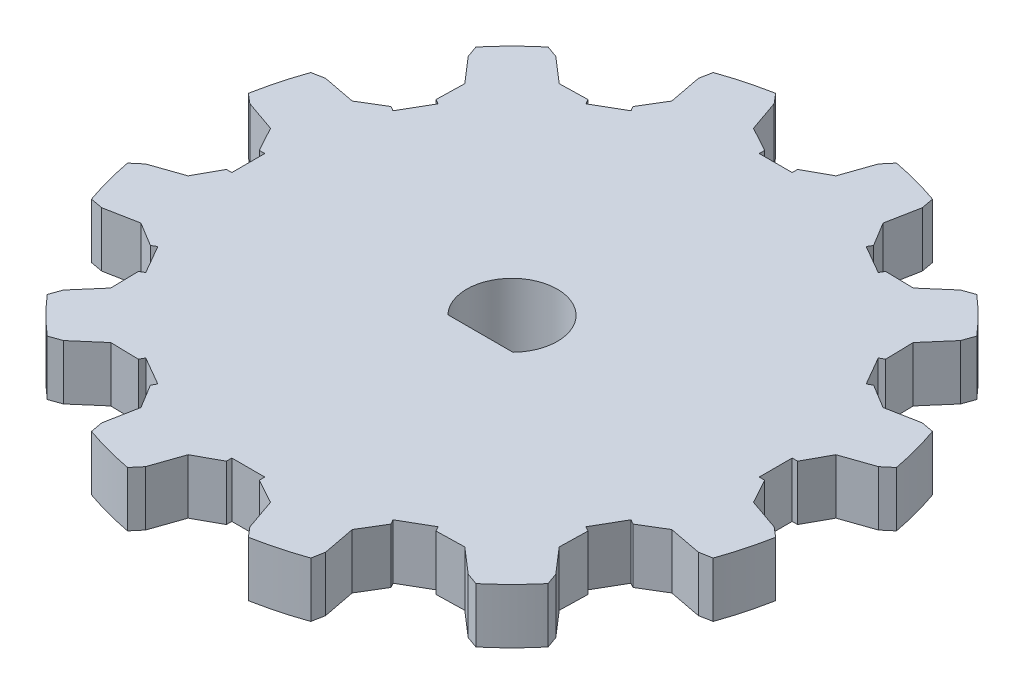
from build123d import *

# Parameters (mm, degrees)
BOSS_EXTRUDE1_DEPTH     = 5
SKETCH5_R               = 17.5
BOSS_EXTRUDE2_DEPTH     = 2.5
CUT_EXTRUDE2_DEPTH      = 1
CUT_EXTRUDE2_DEPTH_BACK = 8.5


with BuildPart() as part:
    # Sketch1 → Boss-Extrude1 (new body)
    with BuildSketch(Plane(origin=(0, 0, 0), x_dir=(1, 0, 0), z_dir=(0, 1, 0))):
        with BuildLine():
            Line((-1.5, 24.494818027), (-3.75, 25.728146066))
            Line((-3.75, 25.728146066), (-4.75, 28.608346684))
            Line((-4.75, 28.608346684), (-5.5, 29.491524206))
            ThreePointArc((-5.5, 29.491524206), (-6.518225952, 29.283318296), (-7.528629065, 29.039968051))
            ThreePointArc((-7.528629065, 29.039968051), (-7.764571353, 28.977774789), (-8, 28.91366459))
            ThreePointArc((-8, 28.91366459), (-8.996709886, 28.619210528), (-9.982622382, 28.290409159))
            Line((-9.982622382, 28.290409159), (-10.190552674, 27.150554989))
            Line((-10.190552674, 27.150554989), (-9.616477769, 24.156228086))
            Line((-9.616477769, 24.156228086), (-10.948370908, 21.963134673))
            Line((-10.948370908, 21.963134673), (-10.700961894, 21.534609691))
            Line((-10.700961894, 21.534609691), (-13.299038106, 20.034609691))
            Line((-13.299038106, 20.034609691), (-13.546447119, 20.463134673))
            Line((-13.546447119, 20.463134673), (-16.111668297, 20.406228086))
            Line((-16.111668297, 20.406228086), (-18.41779401, 22.400554989))
            Line((-18.41779401, 22.400554989), (-19.508901824, 22.790409159))
            ThreePointArc((-19.508901824, 22.790409159), (-20.28660841, 22.100984575), (-21.039968051, 21.385035525))
            ThreePointArc((-21.039968051, 21.385035525), (-21.213203436, 21.213203436), (-21.385035525, 21.039968051))
            ThreePointArc((-21.385035525, 21.039968051), (-22.100984575, 20.28660841), (-22.790409159, 19.508901824))
            Line((-22.790409159, 19.508901824), (-22.400554989, 18.41779401))
            Line((-22.400554989, 18.41779401), (-20.406228086, 16.111668297))
            Line((-20.406228086, 16.111668297), (-20.463134673, 13.546447119))
            Line((-20.463134673, 13.546447119), (-20.034609691, 13.299038106))
            Line((-20.034609691, 13.299038106), (-21.534609691, 10.700961894))
            Line((-21.534609691, 10.700961894), (-21.963134673, 10.948370908))
            Line((-21.963134673, 10.948370908), (-24.156228086, 9.616477769))
            Line((-24.156228086, 9.616477769), (-27.150554989, 10.190552674))
            Line((-27.150554989, 10.190552674), (-28.290409159, 9.982622382))
            ThreePointArc((-28.290409159, 9.982622382), (-28.619210528, 8.996709886), (-28.91366459, 8))
            ThreePointArc((-28.91366459, 8), (-28.977774789, 7.764571353), (-29.039968051, 7.528629065))
            ThreePointArc((-29.039968051, 7.528629065), (-29.283318296, 6.518225952), (-29.491524206, 5.5))
            Line((-29.491524206, 5.5), (-28.608346684, 4.75))
            Line((-28.608346684, 4.75), (-25.728146066, 3.75))
            Line((-25.728146066, 3.75), (-24.494818027, 1.5))
            Line((-24.494818027, 1.5), (-24, 1.5))
            Line((-24, 1.5), (-24, -1.5))
            Line((-24, -1.5), (-24.494818027, -1.5))
            Line((-24.494818027, -1.5), (-25.728146066, -3.75))
            Line((-25.728146066, -3.75), (-28.608346684, -4.75))
            Line((-28.608346684, -4.75), (-29.491524206, -5.5))
            ThreePointArc((-29.491524206, -5.5), (-29.283318296, -6.518225952), (-29.039968051, -7.528629065))
            ThreePointArc((-29.039968051, -7.528629065), (-28.977774789, -7.764571353), (-28.91366459, -8))
            ThreePointArc((-28.91366459, -8), (-28.619210528, -8.996709886), (-28.290409159, -9.982622382))
            Line((-28.290409159, -9.982622382), (-27.150554989, -10.190552674))
            Line((-27.150554989, -10.190552674), (-24.156228086, -9.616477769))
            Line((-24.156228086, -9.616477769), (-21.963134673, -10.948370908))
            Line((-21.963134673, -10.948370908), (-21.534609691, -10.700961894))
            Line((-21.534609691, -10.700961894), (-20.034609691, -13.299038106))
            Line((-20.034609691, -13.299038106), (-20.463134673, -13.546447119))
            Line((-20.463134673, -13.546447119), (-20.406228086, -16.111668297))
            Line((-20.406228086, -16.111668297), (-22.400554989, -18.41779401))
            Line((-22.400554989, -18.41779401), (-22.790409159, -19.508901824))
            ThreePointArc((-22.790409159, -19.508901824), (-22.100984575, -20.28660841), (-21.385035525, -21.039968051))
            ThreePointArc((-21.385035525, -21.039968051), (-21.213203436, -21.213203436), (-21.039968051, -21.385035525))
            ThreePointArc((-21.039968051, -21.385035525), (-20.28660841, -22.100984575), (-19.508901824, -22.790409159))
            Line((-19.508901824, -22.790409159), (-18.41779401, -22.400554989))
            Line((-18.41779401, -22.400554989), (-16.111668297, -20.406228086))
            Line((-16.111668297, -20.406228086), (-13.546447119, -20.463134673))
            Line((-13.546447119, -20.463134673), (-13.299038106, -20.034609691))
            Line((-13.299038106, -20.034609691), (-10.700961894, -21.534609691))
            Line((-10.700961894, -21.534609691), (-10.948370908, -21.963134673))
            Line((-10.948370908, -21.963134673), (-9.616477769, -24.156228086))
            Line((-9.616477769, -24.156228086), (-10.190552674, -27.150554989))
            Line((-10.190552674, -27.150554989), (-9.982622382, -28.290409159))
            ThreePointArc((-9.982622382, -28.290409159), (-8.996709886, -28.619210528), (-8, -28.91366459))
            ThreePointArc((-8, -28.91366459), (-7.764571353, -28.977774789), (-7.528629065, -29.039968051))
            ThreePointArc((-7.528629065, -29.039968051), (-6.518225952, -29.283318296), (-5.5, -29.491524206))
            Line((-5.5, -29.491524206), (-4.75, -28.608346684))
            Line((-4.75, -28.608346684), (-3.75, -25.728146066))
            Line((-3.75, -25.728146066), (-1.5, -24.494818027))
            Line((-1.5, -24.494818027), (-1.5, -24))
            Line((-1.5, -24), (1.5, -24))
            Line((1.5, -24), (1.5, -24.494818027))
            Line((1.5, -24.494818027), (3.75, -25.728146066))
            Line((3.75, -25.728146066), (4.75, -28.608346684))
            Line((4.75, -28.608346684), (5.5, -29.491524206))
            ThreePointArc((5.5, -29.491524206), (6.518225952, -29.283318296), (7.528629065, -29.039968051))
            ThreePointArc((7.528629065, -29.039968051), (7.764571353, -28.977774789), (8, -28.91366459))
            ThreePointArc((8, -28.91366459), (8.996709886, -28.619210528), (9.982622382, -28.290409159))
            Line((9.982622382, -28.290409159), (10.190552674, -27.150554989))
            Line((10.190552674, -27.150554989), (9.616477769, -24.156228086))
            Line((9.616477769, -24.156228086), (10.948370908, -21.963134673))
            Line((10.948370908, -21.963134673), (10.700961894, -21.534609691))
            Line((10.700961894, -21.534609691), (13.299038106, -20.034609691))
            Line((13.299038106, -20.034609691), (13.546447119, -20.463134673))
            Line((13.546447119, -20.463134673), (16.111668297, -20.406228086))
            Line((16.111668297, -20.406228086), (18.41779401, -22.400554989))
            Line((18.41779401, -22.400554989), (19.508901824, -22.790409159))
            ThreePointArc((19.508901824, -22.790409159), (20.28660841, -22.100984575), (21.039968051, -21.385035525))
            ThreePointArc((21.039968051, -21.385035525), (21.213203436, -21.213203436), (21.385035525, -21.039968051))
            ThreePointArc((21.385035525, -21.039968051), (22.100984575, -20.28660841), (22.790409159, -19.508901824))
            Line((22.790409159, -19.508901824), (22.400554989, -18.41779401))
            Line((22.400554989, -18.41779401), (20.406228086, -16.111668297))
            Line((20.406228086, -16.111668297), (20.463134673, -13.546447119))
            Line((20.463134673, -13.546447119), (20.034609691, -13.299038106))
            Line((20.034609691, -13.299038106), (21.534609691, -10.700961894))
            Line((21.534609691, -10.700961894), (21.963134673, -10.948370908))
            Line((21.963134673, -10.948370908), (24.156228086, -9.616477769))
            Line((24.156228086, -9.616477769), (27.150554989, -10.190552674))
            Line((27.150554989, -10.190552674), (28.290409159, -9.982622382))
            ThreePointArc((28.290409159, -9.982622382), (28.619210528, -8.996709886), (28.91366459, -8))
            ThreePointArc((28.91366459, -8), (28.977774789, -7.764571353), (29.039968051, -7.528629065))
            ThreePointArc((29.039968051, -7.528629065), (29.283318296, -6.518225952), (29.491524206, -5.5))
            Line((29.491524206, -5.5), (28.608346684, -4.75))
            Line((28.608346684, -4.75), (25.728146066, -3.75))
            Line((25.728146066, -3.75), (24.494818027, -1.5))
            Line((24.494818027, -1.5), (24, -1.5))
            Line((24, -1.5), (24, 1.5))
            Line((24, 1.5), (24.494818027, 1.5))
            Line((24.494818027, 1.5), (25.728146066, 3.75))
            Line((25.728146066, 3.75), (28.608346684, 4.75))
            Line((28.608346684, 4.75), (29.491524206, 5.5))
            ThreePointArc((29.491524206, 5.5), (29.283318296, 6.518225952), (29.039968051, 7.528629065))
            ThreePointArc((29.039968051, 7.528629065), (28.977774789, 7.764571353), (28.91366459, 8))
            ThreePointArc((28.91366459, 8), (28.619210528, 8.996709886), (28.290409159, 9.982622382))
            Line((28.290409159, 9.982622382), (27.150554989, 10.190552674))
            Line((27.150554989, 10.190552674), (24.156228086, 9.616477769))
            Line((24.156228086, 9.616477769), (21.963134673, 10.948370908))
            Line((21.963134673, 10.948370908), (21.534609691, 10.700961894))
            Line((21.534609691, 10.700961894), (20.034609691, 13.299038106))
            Line((20.034609691, 13.299038106), (20.463134673, 13.546447119))
            Line((20.463134673, 13.546447119), (20.406228086, 16.111668297))
            Line((20.406228086, 16.111668297), (22.400554989, 18.41779401))
            Line((22.400554989, 18.41779401), (22.790409159, 19.508901824))
            ThreePointArc((22.790409159, 19.508901824), (22.100984575, 20.28660841), (21.385035525, 21.039968051))
            ThreePointArc((21.385035525, 21.039968051), (21.213203436, 21.213203436), (21.039968051, 21.385035525))
            ThreePointArc((21.039968051, 21.385035525), (20.28660841, 22.100984575), (19.508901824, 22.790409159))
            Line((19.508901824, 22.790409159), (18.41779401, 22.400554989))
            Line((18.41779401, 22.400554989), (16.111668297, 20.406228086))
            Line((16.111668297, 20.406228086), (13.546447119, 20.463134673))
            Line((13.546447119, 20.463134673), (13.299038106, 20.034609691))
            Line((13.299038106, 20.034609691), (10.700961894, 21.534609691))
            Line((10.700961894, 21.534609691), (10.948370908, 21.963134673))
            Line((10.948370908, 21.963134673), (9.616477769, 24.156228086))
            Line((9.616477769, 24.156228086), (10.190552674, 27.150554989))
            Line((10.190552674, 27.150554989), (9.982622382, 28.290409159))
            ThreePointArc((9.982622382, 28.290409159), (8.996709886, 28.619210528), (8, 28.91366459))
            ThreePointArc((8, 28.91366459), (7.764571353, 28.977774789), (7.528629065, 29.039968051))
            ThreePointArc((7.528629065, 29.039968051), (6.518225952, 29.283318296), (5.5, 29.491524206))
            Line((5.5, 29.491524206), (4.75, 28.608346684))
            Line((4.75, 28.608346684), (3.75, 25.728146066))
            Line((3.75, 25.728146066), (1.5, 24.494818027))
            Line((1.5, 24.494818027), (1.5, 24))
            Line((1.5, 24), (-1.5, 24))
            Line((-1.5, 24), (-1.5, 24.494818027))
        make_face()
    extrude(amount=BOSS_EXTRUDE1_DEPTH)

    # Sketch5 → Boss-Extrude2 (add)
    with BuildSketch(Plane.XZ):
        Circle(SKETCH5_R)
    extrude(amount=BOSS_EXTRUDE2_DEPTH)

    # Sketch6 → Cut-Extrude2 (cut, two sides)
    with BuildSketch(Plane.XZ.offset(2.5)) as cut_extrude2_sk:
        with BuildLine():
            ThreePointArc((4.125, 0), (3.82214204, 1.551404275), (2.958039892, 2.875))
            Line((2.958039892, 2.875), (-2.958039892, 2.875))
            ThreePointArc((-2.958039892, 2.875), (-1.551404275, -3.82214204), (4.125, 0))
        make_face()
    extrude(amount=CUT_EXTRUDE2_DEPTH, mode=Mode.SUBTRACT)
    extrude(cut_extrude2_sk.sketch, amount=-CUT_EXTRUDE2_DEPTH_BACK, mode=Mode.SUBTRACT)


solid = part.part
